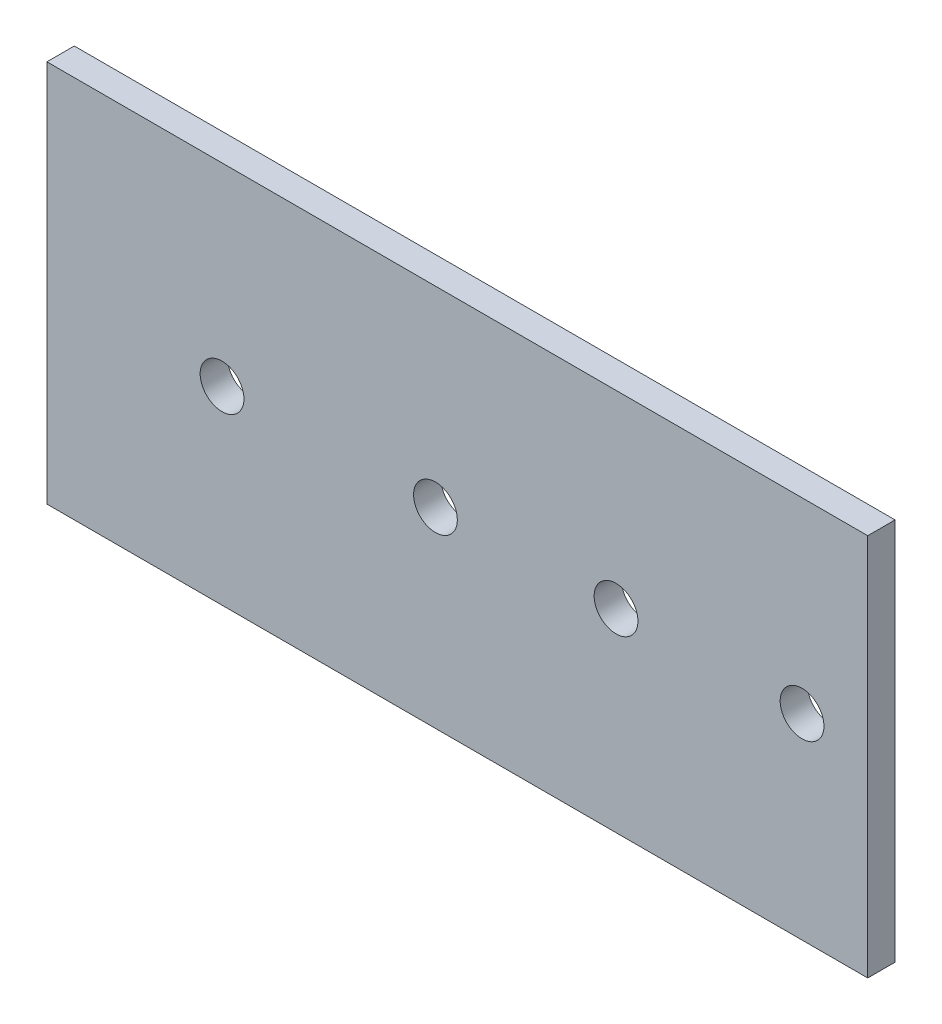
from build123d import *

# Parameters (mm, degrees)
SKETCH1_W           = 150
SKETCH1_H           = 70
BOSS_EXTRUDE1_DEPTH = 2.5
SKETCH2_R           = 4
CUT_EXTRUDE1_DEPTH  = 6


with BuildPart() as part:
    # Sketch1 → Boss-Extrude1 (new body, symmetric)
    with BuildSketch(Plane.XY):
        Rectangle(SKETCH1_W, SKETCH1_H)
    extrude(amount=BOSS_EXTRUDE1_DEPTH, both=True)

    # Sketch2 → Cut-Extrude1 (cut, through all)
    with BuildSketch(Plane.XY.offset(2.5)):
        with Locations((63, 0.85119924)):
            Circle(SKETCH2_R)
        with Locations((29.002241117, 0.460826454)):
            Circle(SKETCH2_R)
        with Locations((-42.995335398, -0.365871995)):
            Circle(SKETCH2_R)
        with Locations((-3.99705162, 0)):
            Circle(SKETCH2_R)
    extrude(amount=-CUT_EXTRUDE1_DEPTH, mode=Mode.SUBTRACT)


solid = part.part
